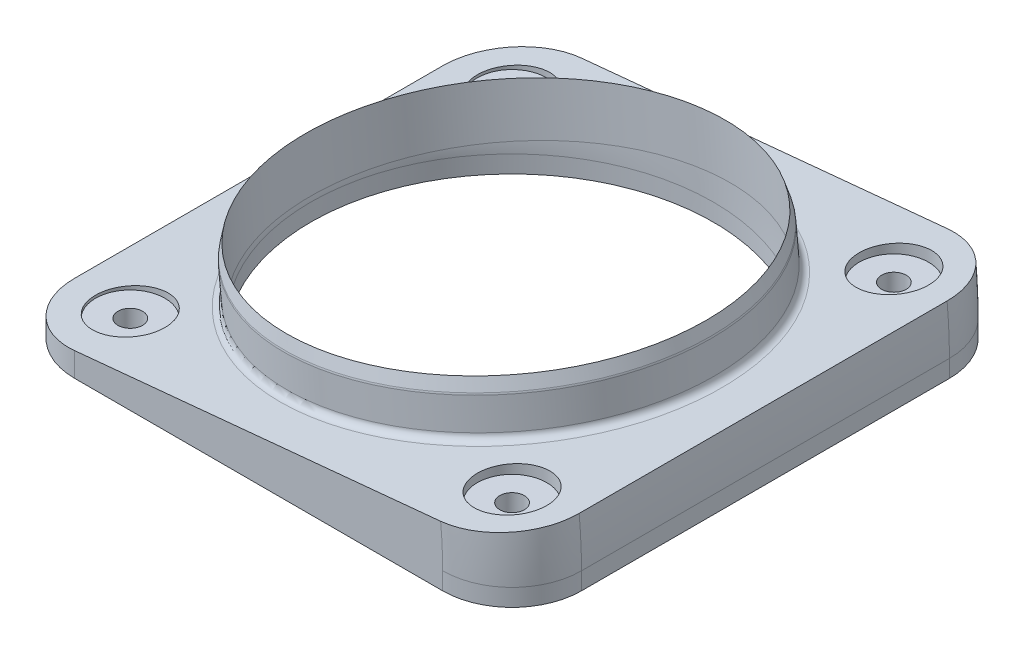
from build123d import *

# Parameters (mm, degrees)
SKETCH1_W           = 92.71
SKETCH1_H           = 92.71
SKETCH1_R           = 36.83
BOSS_EXTRUDE1_DEPTH = 3.175
SKETCH1_2_W         = 92.71
SKETCH1_2_H         = 92.71
SKETCH1_2_R         = 36.83
REVOLVE2_ANGLE      = 5.5
SKETCH2_R           = 2.25
CUT_EXTRUDE1_DEPTH  = 67.6561054
CIRPATTERN1_COUNT   = 4
FILLET1_R           = 12.7
FILLET2_R           = 1.27
SKETCH6_R           = 6.35
CUT_EXTRUDE2_DEPTH  = 68.839640936
SKETCH7_R           = 6.35
CUT_EXTRUDE3_DEPTH  = 67.598633604


with BuildPart() as part:
    # Sketch1 → Boss-Extrude1 (new body)
    with BuildSketch(Plane(origin=(0, 0, 0), x_dir=(1, 0, 0), z_dir=(0, 1, 0))):
        Rectangle(SKETCH1_W, SKETCH1_H)
        Circle(SKETCH1_R, mode=Mode.SUBTRACT)
    extrude(amount=-BOSS_EXTRUDE1_DEPTH)

    # Sketch1_2 → Revolve2 (revolve)
    with BuildSketch(Plane(origin=(0, 0, 0), x_dir=(1, 0, 0), z_dir=(0, 1, 0))):
        Rectangle(SKETCH1_2_W, SKETCH1_2_H)
        Circle(SKETCH1_2_R, mode=Mode.SUBTRACT)
    revolve(axis=Axis((-46.355, 0, 46.355), (0, 0, 1)), revolution_arc=REVOLVE2_ANGLE)

    # Sketch2 → Cut-Extrude1 (cut, through all)
    with BuildSketch(Plane(origin=(0, -3.175, 0), x_dir=(-1, 0, 0), z_dir=(0, -1, 0))):
        with Locations((-34.925, 34.925)):
            Circle(SKETCH2_R)
    cut_extrude1 = extrude(amount=-CUT_EXTRUDE1_DEPTH, mode=Mode.SUBTRACT)

    # CirPattern1: Cut-Extrude1 ×4 about axis
    cirpattern1_axis = Axis((0, -3.175, 0), (0, 1, 0))
    for i in range(1, CIRPATTERN1_COUNT):
        add(cut_extrude1.rotate(cirpattern1_axis, i * 360 / CIRPATTERN1_COUNT), mode=Mode.SUBTRACT)

    # Fillet1
    fillet1_edges = [part.edges().sort_by_distance(p)[0] for p in [
        (-46.355, -1.5875, -46.355),
        (-46.355, -1.5875, 46.355),
        (46.355, -1.5875, 46.355),
        (46.355, -1.5875, -46.355),
        (46.248233911, 4.448052295, 46.355),
        (46.248233911, 4.448052295, -46.355),
    ]]
    fillet(fillet1_edges, radius=FILLET1_R)

    # Sketch4 → Revolve1 (revolve)
    with BuildSketch(Plane.XY):
        Polygon((-37.505927797, 0.85206874), (-36.873851211, 0.912930793), (-37.786782003, 10.394079582), (-38.191718316, 7.974275596), align=None)
    revolve(axis=Axis((96.058179251, -995.375743999, 0), (-0.09584575252022438, 0.9953961983671787, 0)))

    # Fillet2
    fillet2_edges = [part.edges().sort_by_distance(p)[0] for p in [
        (36.393318828, 15.155997833, 0),
        (37.079109347, 8.033790976, 0),
    ]]
    fillet(fillet2_edges, radius=FILLET2_R)

    # Sketch6 → Cut-Extrude2 (cut, through all)
    with BuildSketch(Plane(origin=(0, 0, 0), x_dir=(-1, 0, 0), z_dir=(0, -1, 0))):
        with Locations((34.925, -34.925)):
            Circle(SKETCH6_R)
        with Locations((34.925, 34.925)):
            Circle(SKETCH6_R)
    extrude(amount=-CUT_EXTRUDE2_DEPTH, mode=Mode.SUBTRACT)

    # Sketch7 → Cut-Extrude3 (cut, through all)
    with BuildSketch(Plane(origin=(0, 5.715, 0), x_dir=(-1, 0, 0), z_dir=(0, -1, 0))):
        with Locations((-34.925, 34.925)):
            Circle(SKETCH7_R)
        with Locations((-34.925, -34.925)):
            Circle(SKETCH7_R)
    extrude(amount=-CUT_EXTRUDE3_DEPTH, mode=Mode.SUBTRACT)


solid = part.part
